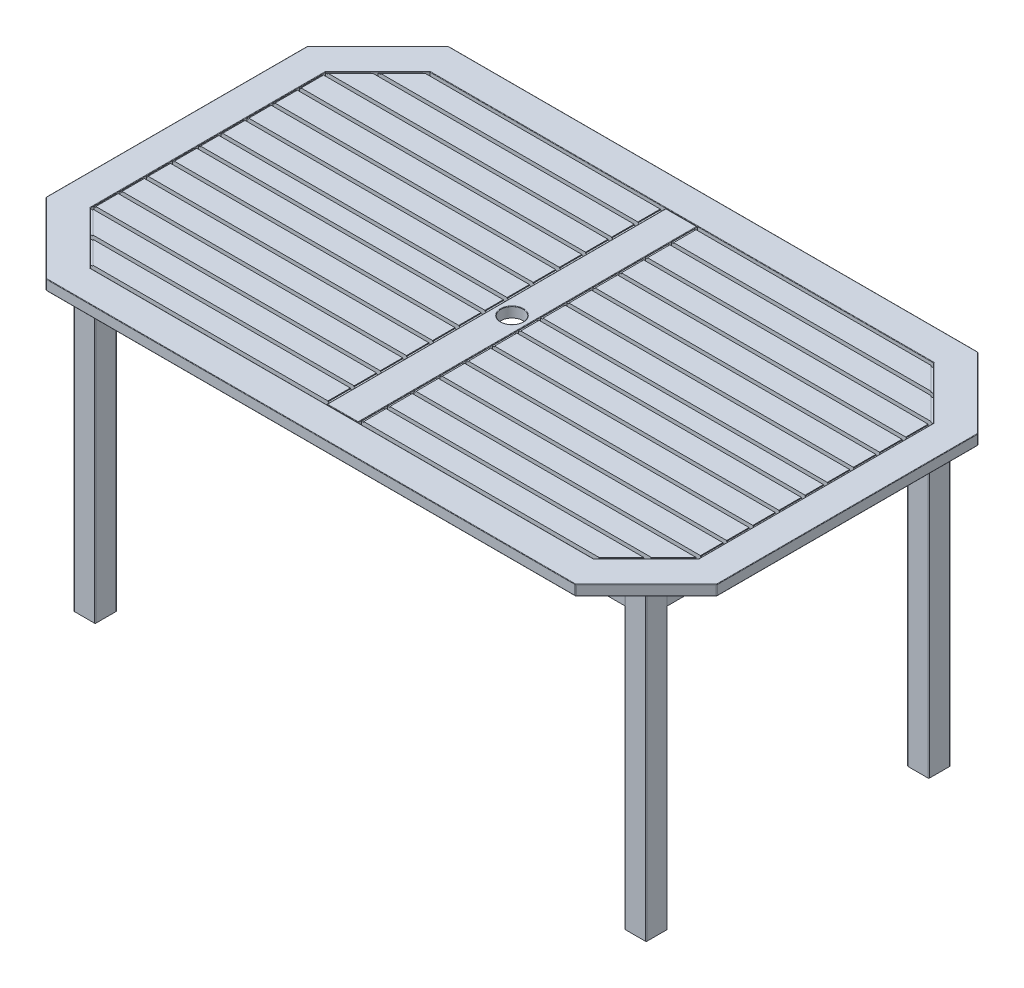
from build123d import *

# Parameters (mm, degrees)
BOSS_EXTRU_1_DEPTH      = 700
BOSS_EXTRU_1_2_DEPTH    = 700
BOSS_EXTRU_1_3_DEPTH    = 700
BOSS_EXTRU_1_4_DEPTH    = 700
ESQUISSE3_R             = 25
BOSS_EXTRU_4_DEPTH      = 23
ESQUISSE4_W             = 1184
ESQUISSE4_H             = 23
ESQUISSE4_W_2           = 23
ESQUISSE4_H_2           = 584
BOSS_EXTRU_6_DEPTH      = 75
ESQUISSE5_W             = 50
ESQUISSE5_H             = 760
BOSS_EXTRU_7_DEPTH      = 12
BOSS_EXTRU_7_2_DEPTH    = 12
ESQUISSE6_W             = 645
ESQUISSE6_H             = 50
ESQUISSE6_H_2           = 41.035354438
BOSS_EXTRU_8_DEPTH      = 11
ENL_V_MAT_EXTRU_1_DEPTH = 2
CONG_1_R                = 4
CONG_2_R                = 1


with BuildPart() as part:
    # Esquisse1 → Boss.-Extru.1 (new body)
    with BuildSketch(Plane(origin=(0, 0, 0), x_dir=(1, 0, 0), z_dir=(0, 1, 0))):
        with BuildLine():
            Line((-638.5, 340), (-593.5, 340))
            ThreePointArc((-593.5, 340), (-592.439339828, 339.560660172), (-592, 338.5))
            Line((-592, 338.5), (-592, 293.5))
            ThreePointArc((-592, 293.5), (-592.439339828, 292.439339828), (-593.5, 292))
            Line((-593.5, 292), (-638.5, 292))
            ThreePointArc((-638.5, 292), (-639.560660172, 292.439339828), (-640, 293.5))
            Line((-640, 293.5), (-640, 338.5))
            ThreePointArc((-640, 338.5), (-639.560660172, 339.560660172), (-638.5, 340))
        make_face()
    extrude(amount=-BOSS_EXTRU_1_DEPTH)



with BuildPart() as body_2:
    # Esquisse1 → Boss.-Extru.1 2 (new body)
    with BuildSketch(Plane(origin=(0, 0, 0), x_dir=(1, 0, 0), z_dir=(0, 1, 0))):
        with BuildLine():
            Line((593.5, 292), (638.5, 292))
            ThreePointArc((638.5, 292), (639.560660172, 292.439339828), (640, 293.5))
            Line((640, 293.5), (640, 338.5))
            ThreePointArc((640, 338.5), (639.560660172, 339.560660172), (638.5, 340))
            Line((638.5, 340), (593.5, 340))
            ThreePointArc((593.5, 340), (592.439339828, 339.560660172), (592, 338.5))
            Line((592, 338.5), (592, 293.5))
            ThreePointArc((592, 293.5), (592.439339828, 292.439339828), (593.5, 292))
        make_face()
    extrude(amount=-BOSS_EXTRU_1_2_DEPTH)


with BuildPart() as body_3:
    # Esquisse1 → Boss.-Extru.1 3 (new body)
    with BuildSketch(Plane(origin=(0, 0, 0), x_dir=(1, 0, 0), z_dir=(0, 1, 0))):
        with BuildLine():
            Line((638.5, -292), (593.5, -292))
            ThreePointArc((593.5, -292), (592.439339828, -292.439339828), (592, -293.5))
            Line((592, -293.5), (592, -338.5))
            ThreePointArc((592, -338.5), (592.439339828, -339.560660172), (593.5, -340))
            Line((593.5, -340), (638.5, -340))
            ThreePointArc((638.5, -340), (639.560660172, -339.560660172), (640, -338.5))
            Line((640, -338.5), (640, -293.5))
            ThreePointArc((640, -293.5), (639.560660172, -292.439339828), (638.5, -292))
        make_face()
    extrude(amount=-BOSS_EXTRU_1_3_DEPTH)


with BuildPart() as body_4:
    # Esquisse1 → Boss.-Extru.1 4 (new body)
    with BuildSketch(Plane(origin=(0, 0, 0), x_dir=(1, 0, 0), z_dir=(0, 1, 0))):
        with BuildLine():
            Line((-593.5, -340), (-638.5, -340))
            ThreePointArc((-638.5, -340), (-639.560660172, -339.560660172), (-640, -338.5))
            Line((-640, -338.5), (-640, -293.5))
            ThreePointArc((-640, -293.5), (-639.560660172, -292.439339828), (-638.5, -292))
            Line((-638.5, -292), (-593.5, -292))
            ThreePointArc((-593.5, -292), (-592.439339828, -292.439339828), (-592, -293.5))
            Line((-592, -293.5), (-592, -338.5))
            ThreePointArc((-592, -338.5), (-592.439339828, -339.560660172), (-593.5, -340))
        make_face()
    extrude(amount=-BOSS_EXTRU_1_4_DEPTH)


with BuildPart() as part_1:
    add(part.part)

    add(body_2.part)  # Boss.-Extru.4 merges body 2

    add(body_3.part)  # Boss.-Extru.4 merges body 3

    add(body_4.part)  # Boss.-Extru.4 merges body 4
    # Esquisse3 → Boss.-Extru.4 (add)
    with BuildSketch(Plane(origin=(0, 0, 0), x_dir=(1, 0, 0), z_dir=(0, 1, 0))):
        Polygon((-592, 450), (592, 450), (750, 292), (750, -292), (592, -450), (-592, -450), (-750, -292), (-750, 292), align=None)
        Circle(ESQUISSE3_R, mode=Mode.SUBTRACT)
        Polygon((-563.005050634, 380), (-35, 380), (-35, -380), (-563.005050634, -380), (-680, -263.005050634), (-680, 263.005050634), align=None, mode=Mode.SUBTRACT)
        Polygon((563.005050634, 380), (680, 263.005050634), (680, -263.005050634), (563.005050634, -380), (35, -380), (35, 380), align=None, mode=Mode.SUBTRACT)
    extrude(amount=BOSS_EXTRU_4_DEPTH)

    # Esquisse4 → Boss.-Extru.6 (add)
    with BuildSketch(Plane(origin=(0, 0, 0), x_dir=(1, 0, 0), z_dir=(0, 1, 0))):
        with Locations((0, 327)):
            Rectangle(ESQUISSE4_W, ESQUISSE4_H)
        with Locations((627, 0)):
            Rectangle(ESQUISSE4_W_2, ESQUISSE4_H_2)
        with Locations((0, -327)):
            Rectangle(ESQUISSE4_W, ESQUISSE4_H)
        with Locations((-627, 0)):
            Rectangle(ESQUISSE4_W_2, ESQUISSE4_H_2)
    extrude(amount=-BOSS_EXTRU_6_DEPTH)

    # Esquisse6 → Boss.-Extru.8 (add)
    with BuildSketch(Plane(origin=(0, 23, 0), x_dir=(1, 0, 0), z_dir=(0, 1, 0))):
        Polygon((-571.502525317, 371.502525317), (-35, 371.502525317), (-35, 321.502525317), (-621.502525317, 321.502525317), align=None)
        Polygon((-630, 313.005050634), (-35, 313.005050634), (-35, 263.005050634), (-680, 263.005050634), align=None)
        with Locations((-357.5, 229.507575951)):
            Rectangle(ESQUISSE6_W, ESQUISSE6_H)
        with Locations((-357.5, 171.010101268)):
            Rectangle(ESQUISSE6_W, ESQUISSE6_H)
        with Locations((-357.5, 112.512626585)):
            Rectangle(ESQUISSE6_W, ESQUISSE6_H)
        with Locations((-357.5, 54.015151902)):
            Rectangle(ESQUISSE6_W, ESQUISSE6_H)
        with Locations((-357.5, 0)):
            Rectangle(ESQUISSE6_W, ESQUISSE6_H_2)
        with Locations((357.5, 0)):
            Rectangle(ESQUISSE6_W, ESQUISSE6_H_2)
        with Locations((357.5, 54.015151902)):
            Rectangle(ESQUISSE6_W, ESQUISSE6_H)
        with Locations((357.5, 112.512626585)):
            Rectangle(ESQUISSE6_W, ESQUISSE6_H)
        with Locations((357.5, 171.010101268)):
            Rectangle(ESQUISSE6_W, ESQUISSE6_H)
        with Locations((357.5, 229.507575951)):
            Rectangle(ESQUISSE6_W, ESQUISSE6_H)
        Polygon((680, 263.005050634), (630, 313.005050634), (35, 313.005050634), (35, 263.005050634), align=None)
        Polygon((621.502525317, 321.502525317), (571.502525317, 371.502525317), (35, 371.502525317), (35, 321.502525317), align=None)
        Polygon((571.502525317, -371.502525317), (35, -371.502525317), (35, -321.502525317), (621.502525317, -321.502525317), align=None)
        Polygon((630, -313.005050634), (35, -313.005050634), (35, -263.005050634), (680, -263.005050634), align=None)
        with Locations((357.5, -229.507575951)):
            Rectangle(ESQUISSE6_W, ESQUISSE6_H)
        with Locations((357.5, -171.010101268)):
            Rectangle(ESQUISSE6_W, ESQUISSE6_H)
        with Locations((357.5, -112.512626585)):
            Rectangle(ESQUISSE6_W, ESQUISSE6_H)
        with Locations((357.5, -54.015151902)):
            Rectangle(ESQUISSE6_W, ESQUISSE6_H)
        with Locations((-357.5, -54.015151902)):
            Rectangle(ESQUISSE6_W, ESQUISSE6_H)
        with Locations((-357.5, -112.512626585)):
            Rectangle(ESQUISSE6_W, ESQUISSE6_H)
        with Locations((-357.5, -171.010101268)):
            Rectangle(ESQUISSE6_W, ESQUISSE6_H)
        with Locations((-357.5, -229.507575951)):
            Rectangle(ESQUISSE6_W, ESQUISSE6_H)
        Polygon((-680, -263.005050634), (-630, -313.005050634), (-35, -313.005050634), (-35, -263.005050634), align=None)
        Polygon((-621.502525317, -321.502525317), (-571.502525317, -371.502525317), (-35, -371.502525317), (-35, -321.502525317), align=None)
    extrude(amount=-BOSS_EXTRU_8_DEPTH)

    # Esquisse7 → Enlèv. mat.-Extru.1 (cut)
    with BuildSketch(Plane(origin=(0, 23, 0), x_dir=(1, 0, 0), z_dir=(0, 1, 0))):
        Polygon((-563.005050634, 380), (-680, 263.005050634), (-680, -263.005050634), (-563.005050634, -380), (563.005050634, -380), (680, -263.005050634), (680, 263.005050634), (563.005050634, 380), align=None)
        Polygon((561.348196384, 376), (40, 376), (40, -376), (561.348196384, -376), (676, -261.348196384), (676, 261.348196384), align=None, mode=Mode.SUBTRACT)
        Polygon((-561.348196384, 376), (-676, 261.348196384), (-676, -261.348196384), (-561.348196384, -376), (-40, -376), (-40, 376), align=None, mode=Mode.SUBTRACT)
        Polygon((-35, 379), (-35, -376), (-35, -379), (35, -379), (35, -376), (35, 379), align=None, mode=Mode.SUBTRACT)
    extrude(amount=-ENL_V_MAT_EXTRU_1_DEPTH, mode=Mode.SUBTRACT)

    # Congé1
    cong_1_edges = [part_1.edges().sort_by_distance(p)[0] for p in [
        (-592, 11.5, -450),
        (-750, 11.5, -292),
        (-750, 11.5, 292),
        (-592, 11.5, 450),
        (592, 11.5, 450),
        (750, 11.5, 292),
        (750, 11.5, -292),
        (592, 11.5, -450),
    ]]
    fillet(cong_1_edges, radius=CONG_1_R)

    # Congé2
    cong_2_edges = [part_1.edges().sort_by_distance(p)[0] for p in [
        (0, 23, -379),
        (0, 23, 379),
        (671, 0, -371),
        (671, 23, -371),
        (-671, 0, -371),
        (0, 0, -450),
        (750, 0, 0),
        (671, 0, 371),
        (0, 0, 450),
        (-671, 0, 371),
        (-750, 0, 0),
        (591.87387948, 0, 449.69551813),
        (749.69551813, 0, 291.87387948),
        (-591.87387948, 0, 449.69551813),
        (-749.69551813, 0, 291.87387948),
        (-749.69551813, 0, -291.87387948),
        (-591.87387948, 0, -449.69551813),
        (591.87387948, 0, -449.69551813),
        (749.69551813, 0, -291.87387948),
        (750, 23, 0),
        (-671, 23, -371),
        (-750, 23, 0),
        (-671, 23, 371),
        (0, 23, 450),
        (671, 23, 371),
        (0, 23, -450),
        (591.87387948, 23, 449.69551813),
        (749.69551813, 23, 291.87387948),
        (-591.87387948, 23, 449.69551813),
        (-749.69551813, 23, 291.87387948),
        (-749.69551813, 23, -291.87387948),
        (-591.87387948, 23, -449.69551813),
        (591.87387948, 23, -449.69551813),
        (749.69551813, 23, -291.87387948),
        (-35, 23, 0),
        (35, 23, 0),
        (-621.502525317, 23, -321.502525317),
        (-680, 23, 0),
        (621.502525317, 23, -321.502525317),
        (0, 23, 380),
        (0, 23, -380),
        (621.502525317, 23, 321.502525317),
        (680, 23, 0),
        (-25, 23, 0),
        (-621.502525317, 23, 321.502525317),
    ]]
    fillet(cong_2_edges, radius=CONG_2_R)


with BuildPart() as body_2_2:
    # Esquisse5 → Boss.-Extru.7 (new body)
    with BuildSketch(Plane(origin=(0, 0, 0), x_dir=(1, 0, 0), z_dir=(0, 1, 0))):
        with Locations((-505, 0)):
            Rectangle(ESQUISSE5_W, ESQUISSE5_H)
    extrude(amount=BOSS_EXTRU_7_DEPTH)


with BuildPart() as body_3_2:
    # Esquisse5 → Boss.-Extru.7 2 (new body)
    with BuildSketch(Plane(origin=(0, 0, 0), x_dir=(1, 0, 0), z_dir=(0, 1, 0))):
        with Locations((505, 0)):
            Rectangle(ESQUISSE5_W, ESQUISSE5_H)
    extrude(amount=BOSS_EXTRU_7_2_DEPTH)


solid = Compound([part_1.part, body_2_2.part, body_3_2.part])
